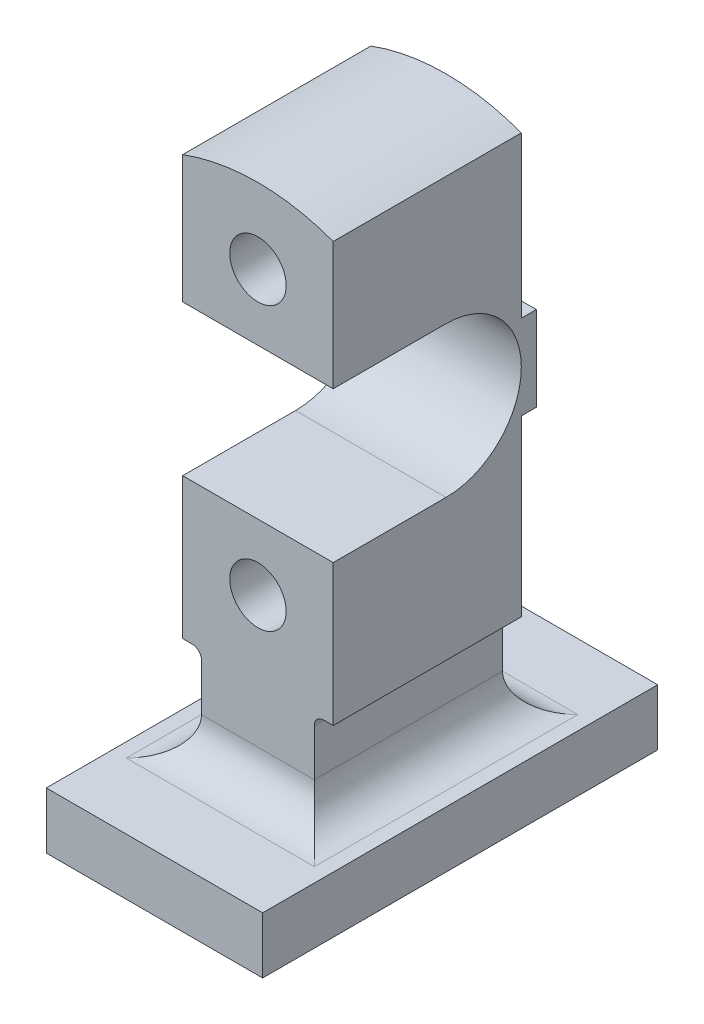
from build123d import *

# Parameters (mm, degrees)
BOSS_EXTRUDE1_DEPTH     = 115
CUT_EXTRUDE4_DEPTH      = 56
CUT_EXTRUDE4_DEPTH_BACK = 156
FILLET1_R               = 20
SKETCH4_R               = 15
CUT_EXTRUDE5_DEPTH      = 56
CUT_EXTRUDE5_DEPTH_BACK = 148


with BuildPart() as part:
    # Sketch1 → Boss-Extrude1 (new body)
    with BuildSketch(Plane(origin=(0, 0, 0), x_dir=(0, 0, -1), z_dir=(1, 0, 0))):
        with BuildLine():
            Line((0, 0), (210, 0))
            Line((210, 0), (210, 30))
            Line((210, 30), (155, 30))
            Line((155, 30), (155, 172.5))
            Line((155, 172.5), (163, 172.5))
            Line((163, 172.5), (163, 217.5))
            Line((163, 217.5), (155, 217.5))
            Line((155, 217.5), (155, 310))
            Line((155, 310), (55, 310))
            Line((55, 310), (55, 235))
            Line((55, 235), (115, 235))
            ThreePointArc((115, 235), (155, 195), (115, 155))
            Line((115, 155), (55, 155))
            Line((55, 155), (55, 30))
            Line((55, 30), (0, 30))
            Line((0, 30), (0, 0))
        make_face()
    extrude(amount=BOSS_EXTRUDE1_DEPTH)

    # Sketch2 → Cut-Extrude4 (cut, two sides)
    with BuildSketch(Plane(origin=(0, 0, -155), x_dir=(-1, 0, 0), z_dir=(0, 0, -1))) as cut_extrude4_sk:
        with BuildLine():
            Line((0, 172.5), (-17.5, 172.5))
            Line((-17.5, 172.5), (-17.5, 80))
            Line((-17.5, 80), (-22.5, 80))
            ThreePointArc((-22.5, 80), (-26.035533906, 78.535533906), (-27.5, 75))
            Line((-27.5, 75), (-27.5, 50))
            ThreePointArc((-27.5, 50), (-21.642135624, 35.857864376), (-7.5, 30))
            Line((-7.5, 30), (0, 30))
            Line((0, 30), (0, 172.5))
        make_face()
        with BuildLine():
            Line((-97.5, 172.5), (-97.5, 302.819293264))
            ThreePointArc((-97.5, 302.819293264), (-77.819710562, 308.190588667), (-57.5, 310))
            Line((-57.5, 310), (-115, 310))
            Line((-115, 310), (-115, 172.5))
            Line((-115, 172.5), (-97.5, 172.5))
        make_face()
        with BuildLine():
            Line((-97.5, 80), (-97.5, 172.5))
            Line((-97.5, 172.5), (-115, 172.5))
            Line((-115, 172.5), (-115, 30))
            Line((-115, 30), (-107.5, 30))
            ThreePointArc((-107.5, 30), (-93.357864376, 35.857864376), (-87.5, 50))
            Line((-87.5, 50), (-87.5, 75))
            ThreePointArc((-87.5, 75), (-88.964466094, 78.535533906), (-92.5, 80))
            Line((-92.5, 80), (-97.5, 80))
        make_face()
        with BuildLine():
            Line((0, 310), (-57.5, 310))
            ThreePointArc((-57.5, 310), (-37.180289438, 308.190588667), (-17.5, 302.819293264))
            Line((-17.5, 302.819293264), (-17.5, 172.5))
            Line((-17.5, 172.5), (0, 172.5))
            Line((0, 172.5), (0, 310))
        make_face()
    extrude(amount=CUT_EXTRUDE4_DEPTH, mode=Mode.SUBTRACT)
    extrude(cut_extrude4_sk.sketch, amount=-CUT_EXTRUDE4_DEPTH_BACK, mode=Mode.SUBTRACT)

    # Fillet1
    fillet1_edges = [part.edges().sort_by_distance(p)[0] for p in [
        (57.5, 30, -155),
        (57.5, 30, -55),
    ]]
    fillet(fillet1_edges, radius=FILLET1_R)

    # Sketch4 → Cut-Extrude5 (cut, two sides)
    with BuildSketch(Plane(origin=(0, 0, -155), x_dir=(-1, 0, 0), z_dir=(0, 0, -1))) as cut_extrude5_sk:
        with Locations((-57.5, 120)):
            Circle(SKETCH4_R)
        with Locations((-57.5, 270)):
            Circle(SKETCH4_R)
    extrude(amount=CUT_EXTRUDE5_DEPTH, mode=Mode.SUBTRACT)
    extrude(cut_extrude5_sk.sketch, amount=-CUT_EXTRUDE5_DEPTH_BACK, mode=Mode.SUBTRACT)


solid = part.part
